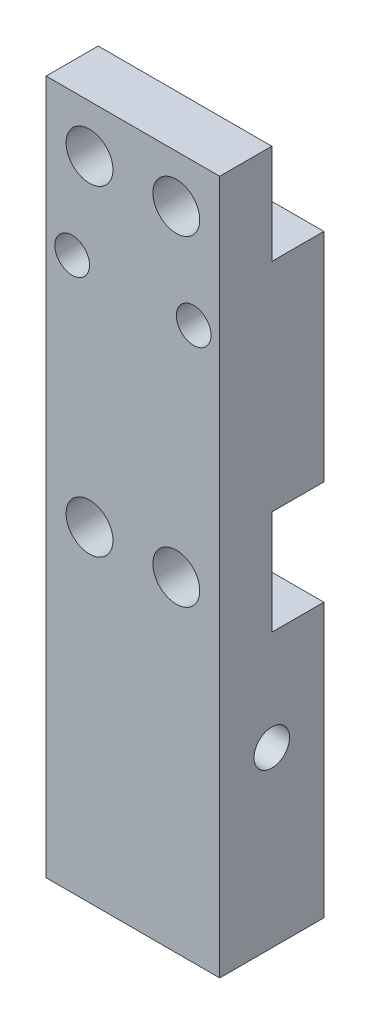
from build123d import *

# Parameters (mm, degrees)
SKETCH1_W                = 10
SKETCH1_H                = 6
BOSS_EXTRUDE1_DEPTH      = 40
M2_5_TAPPED_HOLE1_D      = 2.05
M2_5_TAPPED_HOLE1_DEPTH  = 10
M2_5_TAPPED_HOLE1_TIP    = 0.615882135
M2_5_CLEARANCE_HOLE1_D   = 2.7
F_2_0_2_DIAMETER_HOLE2_D = 2
M2_5_TAPPED_HOLE2_D      = 2.05
SKETCH13_W               = 10
SKETCH13_H               = 6
SKETCH13_H_2             = 5.75
CUT_EXTRUDE2_DEPTH       = 3


with BuildPart() as part:
    # Sketch1 → Boss-Extrude1 (new body)
    with BuildSketch(Plane(origin=(0, 0, 0), x_dir=(1, 0, 0), z_dir=(0, 1, 0))):
        Rectangle(SKETCH1_W, SKETCH1_H)
    extrude(amount=BOSS_EXTRUDE1_DEPTH)

    # M2.5 Tapped Hole1
    with Locations(Plane(origin=(0, 0, 0), x_dir=(-1, 0, 0), z_dir=(0, -1, 0))):
        with Locations((2.5, 0), (-2.5, 0)):
            Hole(M2_5_TAPPED_HOLE1_D / 2, depth=M2_5_TAPPED_HOLE1_DEPTH)
            with Locations((0, 0, -(M2_5_TAPPED_HOLE1_DEPTH + M2_5_TAPPED_HOLE1_TIP / 2))):  # 118° drill point
                Cone(0, M2_5_TAPPED_HOLE1_D / 2, M2_5_TAPPED_HOLE1_TIP, mode=Mode.SUBTRACT)

    # M2.5 Clearance Hole1 (through all)
    with Locations(Plane(origin=(0, 0, -3), x_dir=(-1, 0, 0), z_dir=(0, 0, -1))):
        with Locations((-2.5, 37.25), (2.5, 37.25), (-2.5, 18.75), (2.5, 18.75)):
            Hole(M2_5_CLEARANCE_HOLE1_D / 2)

    # Ø2.0 (2) Diameter Hole2 (through all)
    with Locations(Plane(origin=(0, 0, -3), x_dir=(-1, 0, 0), z_dir=(0, 0, -1))):
        with Locations((3.5, 31.81)):
            f_2_0_2_diameter_hole2 = Hole(F_2_0_2_DIAMETER_HOLE2_D / 2)

    # Mirror1: Ø2.0 (2) Diameter Hole2 across plane
    add(f_2_0_2_diameter_hole2.mirror(Plane(origin=(0, 0, 0), x_dir=(0, 0, 1), z_dir=(1, 0, 0))), mode=Mode.SUBTRACT)

    # M2.5 Tapped Hole2 (through all)
    with Locations(Plane(origin=(5, 0, 0), x_dir=(0, 0, -1), z_dir=(1, 0, 0))):
        with Locations((0, 10)):
            Hole(M2_5_TAPPED_HOLE2_D / 2)

    # Sketch13 → Cut-Extrude2 (cut)
    with BuildSketch(Plane(origin=(0, 0, -3), x_dir=(-1, 0, 0), z_dir=(0, 0, -1))):
        with Locations((0, 18.75)):
            Rectangle(SKETCH13_W, SKETCH13_H)
        with Locations((0, 37.125)):
            Rectangle(SKETCH13_W, SKETCH13_H_2)
    extrude(amount=-CUT_EXTRUDE2_DEPTH, mode=Mode.SUBTRACT)


solid = part.part
